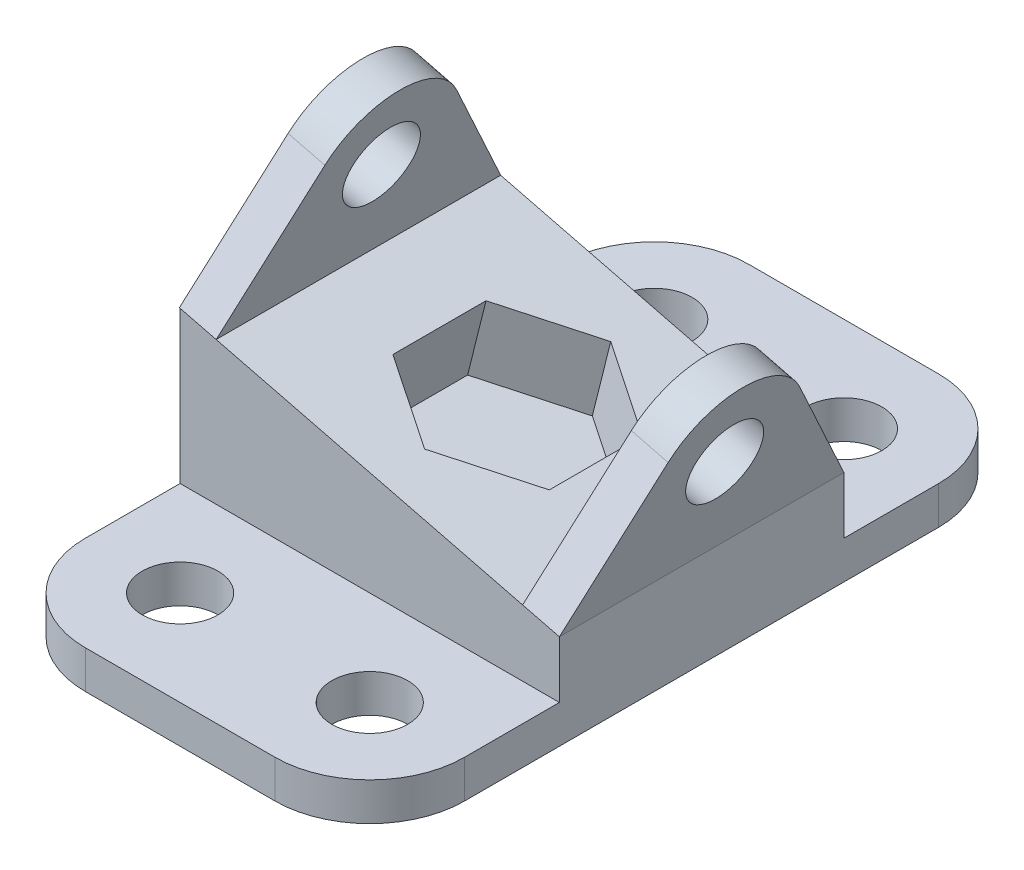
from build123d import *

# Parameters (mm, degrees)
SALIENTE_EXTRUIR1_DEPTH = 60
CROQUIS2_W              = 80
CROQUIS2_H              = 8
SALIENTE_EXTRUIR2_DEPTH = 40
CROQUIS3_R              = 8
SALIENTE_EXTRUIR3_DEPTH = 8
MATRIZL1_COUNT          = 2
MATRIZL1_PITCH          = 74.62
CROQUIS5_R              = 8
CORTAR_EXTRUIR1_DEPTH   = 8
REDONDEO2_R             = 20
CORTAR_EXTRUIR2_DEPTH   = 16


with BuildPart() as part:
    # Croquis1 → Saliente-Extruir1 (new body)
    with BuildSketch(Plane.XY):
        Polygon((0, 0), (80, 0), (80, 20), (0, 40), align=None)
    extrude(amount=SALIENTE_EXTRUIR1_DEPTH)

    # Croquis2 → Saliente-Extruir2 (add)
    with BuildSketch(Plane.XY.offset(60)):
        with Locations((40, 4)):
            Rectangle(CROQUIS2_W, CROQUIS2_H)
    saliente_extruir2 = extrude(amount=SALIENTE_EXTRUIR2_DEPTH)

    # Simetría1: Saliente-Extruir2 across plane
    add(saliente_extruir2.mirror(Plane(origin=(0, 0, 30), x_dir=(1, 0, 0), z_dir=(0, 0, -1))))

    # Croquis3 → Saliente-Extruir3 (add)
    with BuildSketch(Plane(origin=(70.588235294, -17.647058824, 0), x_dir=(0, 0, -1), z_dir=(0.9701425, -0.242535625, 0))):
        with BuildLine():
            Line((-43.861166484, 66.797449732), (-60, 38.805700006))
            Line((-60, 38.805700006), (0, 38.805700006))
            Line((0, 38.805700006), (-16.138833516, 66.797449732))
            ThreePointArc((-16.138833516, 66.797449732), (-30, 74.805700006), (-43.861166484, 66.797449732))
        make_face()
        with Locations((-30, 58.805700006)):
            Circle(CROQUIS3_R, mode=Mode.SUBTRACT)
    saliente_extruir3 = extrude(amount=-SALIENTE_EXTRUIR3_DEPTH)

    # MatrizL1: Saliente-Extruir3 ×2
    with Locations(*[Vector(-0.9701425, 0.242535625, 0) * (i * MATRIZL1_PITCH) for i in range(1, MATRIZL1_COUNT)]):
        add(saliente_extruir3)

    # Croquis5 → Cortar-Extruir1 (cut)
    with BuildSketch(Plane(origin=(0, 8, 0), x_dir=(1, 0, 0), z_dir=(0, 1, 0))):
        with Locations((20, 20)):
            Circle(CROQUIS5_R)
        with Locations((60, 20)):
            Circle(CROQUIS5_R)
        with Locations((60, -80)):
            Circle(CROQUIS5_R)
        with Locations((20, -80)):
            Circle(CROQUIS5_R)
    extrude(amount=-CORTAR_EXTRUIR1_DEPTH, mode=Mode.SUBTRACT)

    # Redondeo2
    redondeo2_edges = [part.edges().sort_by_distance(p)[0] for p in [
        (0, 4, 100),
        (80, 4, 100),
        (0, 4, -40),
        (80, 4, -40),
    ]]
    fillet(redondeo2_edges, radius=REDONDEO2_R)

    # Croquis6 → Cortar-Extruir2 (cut)
    with BuildSketch(Plane(origin=(9.411764706, 37.647058824, 0), x_dir=(0.9701425, -0.242535625, 0), z_dir=(0.242535625, 0.9701425, 0))):
        Polygon((32.760687511, -10.370090848), (15.760687511, -20.185045424), (15.760687511, -39.814954576), (32.760687511, -49.629909152), (49.760687511, -39.814954576), (49.760687511, -20.185045424), align=None)
    extrude(amount=-CORTAR_EXTRUIR2_DEPTH, mode=Mode.SUBTRACT)


solid = part.part
